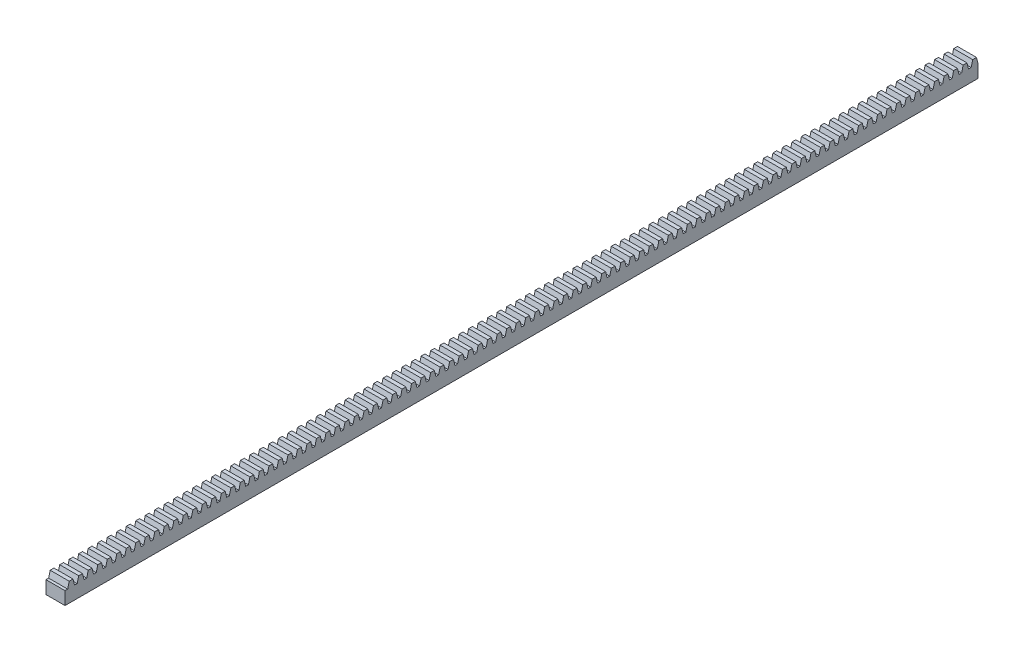
from build123d import *

# Parameters (mm, degrees)
SKETCH1_W           = 6.35
SKETCH1_H           = 4.318
BOSS_EXTRUDE1_DEPTH = 304.8
BOSS_EXTRUDE2_DEPTH = 6.35
LPATTERN1_COUNT     = 96
LPATTERN1_PITCH     = 3.175


with BuildPart() as part:
    # Sketch1 → Boss-Extrude1 (new body)
    with BuildSketch(Plane.XY):
        with Locations((3.175, 2.159)):
            Rectangle(SKETCH1_W, SKETCH1_H)
    extrude(amount=BOSS_EXTRUDE1_DEPTH)

    # Sketch2 → Boss-Extrude2 (add)
    with BuildSketch(Plane(origin=(6.35, 0, 0), x_dir=(0, 0, -1), z_dir=(1, 0, 0))):
        Polygon((0, 4.318), (-2.286, 4.318), (-1.778, 6.35), (-0.508, 6.35), align=None)
    boss_extrude2 = extrude(amount=-BOSS_EXTRUDE2_DEPTH)

    # LPattern1: Boss-Extrude2 ×96
    with Locations(*[(0, 0, i * LPATTERN1_PITCH) for i in range(1, LPATTERN1_COUNT)]):
        add(boss_extrude2)


solid = part.part
